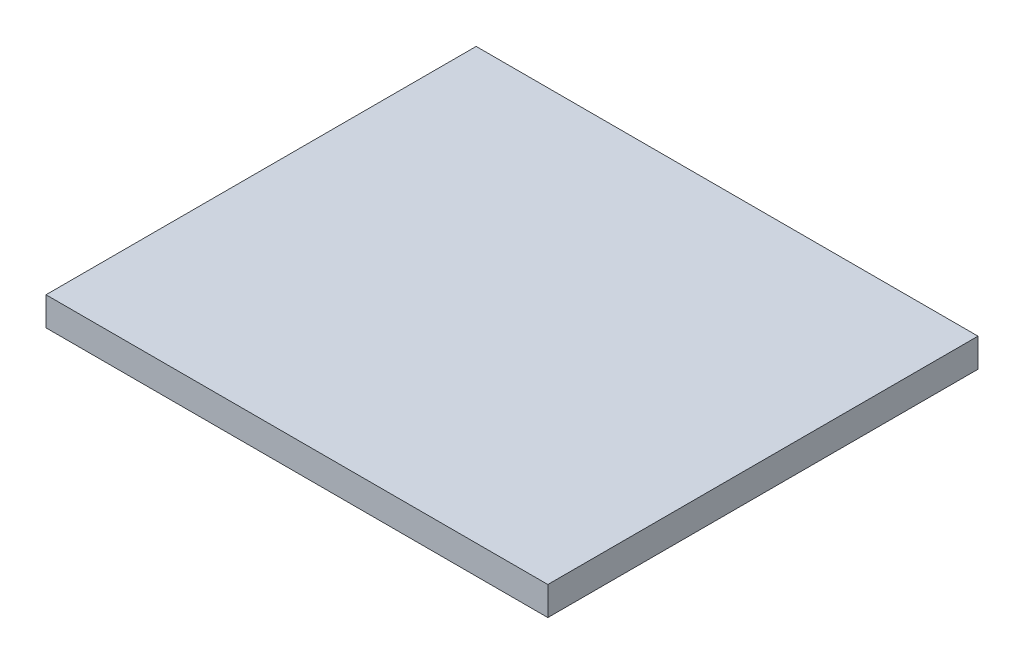
from build123d import *

# Parameters (mm, degrees)
SKETCH1_W           = 350
SKETCH1_H           = 300
BOSS_EXTRUDE1_DEPTH = 20


with BuildPart() as part:
    # Sketch1 → Boss-Extrude1 (new body)
    with BuildSketch(Plane(origin=(0, 0, 0), x_dir=(1, 0, 0), z_dir=(0, 1, 0))):
        with Locations((-175, 150)):
            Rectangle(SKETCH1_W, SKETCH1_H)
    extrude(amount=BOSS_EXTRUDE1_DEPTH)


solid = part.part
